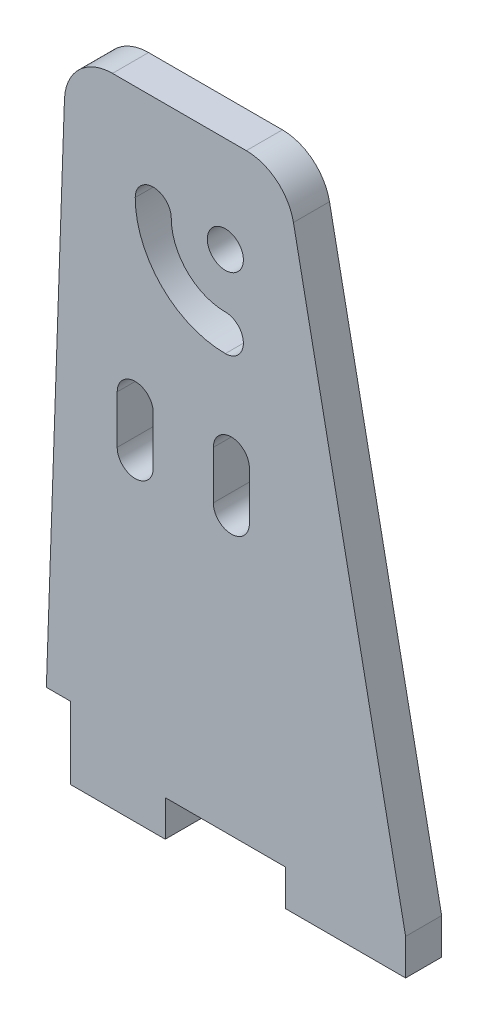
from build123d import *

# Parameters (mm, degrees)
SKETCH1_R           = 1.5
BOSS_EXTRUDE1_DEPTH = 3
CUT_EXTRUDE1_DEPTH  = 4


with BuildPart() as part:
    # Sketch1 → Boss-Extrude1 (new body)
    with BuildSketch(Plane.XY):
        with BuildLine():
            Line((-36.448598131, -26.168224299), (-36.448598131, -23.168224299))
            Line((-36.448598131, -23.168224299), (-34.837367865, 22.971373688))
            ThreePointArc((-34.837367865, 22.971373688), (-33.618438039, 25.709134902), (-30.839804557, 26.831775701))
            Line((-30.839804557, 26.831775701), (-19.702559656, 26.831775701))
            ThreePointArc((-19.702559656, 26.831775701), (-17.165801235, 25.924485955), (-15.779830266, 23.614204058))
            Line((-15.779830266, 23.614204058), (-6.448598131, -23.168224299))
            Line((-6.448598131, -23.168224299), (-6.448598131, -26.168224299))
            Line((-6.448598131, -26.168224299), (-16.448598131, -26.168224299))
            Line((-16.448598131, -26.168224299), (-16.448598131, -23.168224299))
            Line((-16.448598131, -23.168224299), (-26.448598131, -23.168224299))
            Line((-26.448598131, -23.168224299), (-26.448598131, -26.168224299))
            Line((-26.448598131, -26.168224299), (-36.448598131, -26.168224299))
        make_face()
        with Locations((-21.448598131, 18.831775701)):
            Circle(SKETCH1_R, mode=Mode.SUBTRACT)
        with BuildLine():
            Line((-27.448598131, 4.074261176), (-27.448598131, 0.074261176))
            ThreePointArc((-27.448598131, 0.074261176), (-28.948598131, -1.425738824), (-30.448598131, 0.074261176))
            Line((-30.448598131, 0.074261176), (-30.448598131, 4.074261176))
            ThreePointArc((-30.448598131, 4.074261176), (-28.948598131, 5.574261176), (-27.448598131, 4.074261176))
        make_face(mode=Mode.SUBTRACT)
        with BuildLine():
            Line((-19.448598131, 4.074261176), (-19.448598131, 0.074261176))
            ThreePointArc((-19.448598131, 0.074261176), (-20.948598131, -1.425738824), (-22.448598131, 0.074261176))
            Line((-22.448598131, 0.074261176), (-22.448598131, 4.074261176))
            ThreePointArc((-22.448598131, 4.074261176), (-20.948598131, 5.574261176), (-19.448598131, 4.074261176))
        make_face(mode=Mode.SUBTRACT)
        with BuildLine():
            ThreePointArc((-28.948598131, 18.831775701), (-26.75189899, 13.528474842), (-21.448598131, 11.331775701))
            ThreePointArc((-21.448598131, 11.331775701), (-19.948598131, 12.831775701), (-21.448598131, 14.331775701))
            ThreePointArc((-21.448598131, 14.331775701), (-24.630578646, 15.649795186), (-25.948598131, 18.831775701))
            ThreePointArc((-25.948598131, 18.831775701), (-27.448598131, 20.331775701), (-28.948598131, 18.831775701))
        make_face(mode=Mode.SUBTRACT)
    extrude(amount=BOSS_EXTRUDE1_DEPTH)

    # Sketch2 → Cut-Extrude1 (cut, through all)
    with BuildSketch(Plane.XY.offset(3)):
        Polygon((-34.343835822, -26.168224299), (-34.343835822, -20.168224299), (-36.343835822, -20.168224299), (-36.448598131, -23.168224299), (-36.448598131, -26.168224299), align=None)
    extrude(amount=-CUT_EXTRUDE1_DEPTH, mode=Mode.SUBTRACT)


solid = part.part
